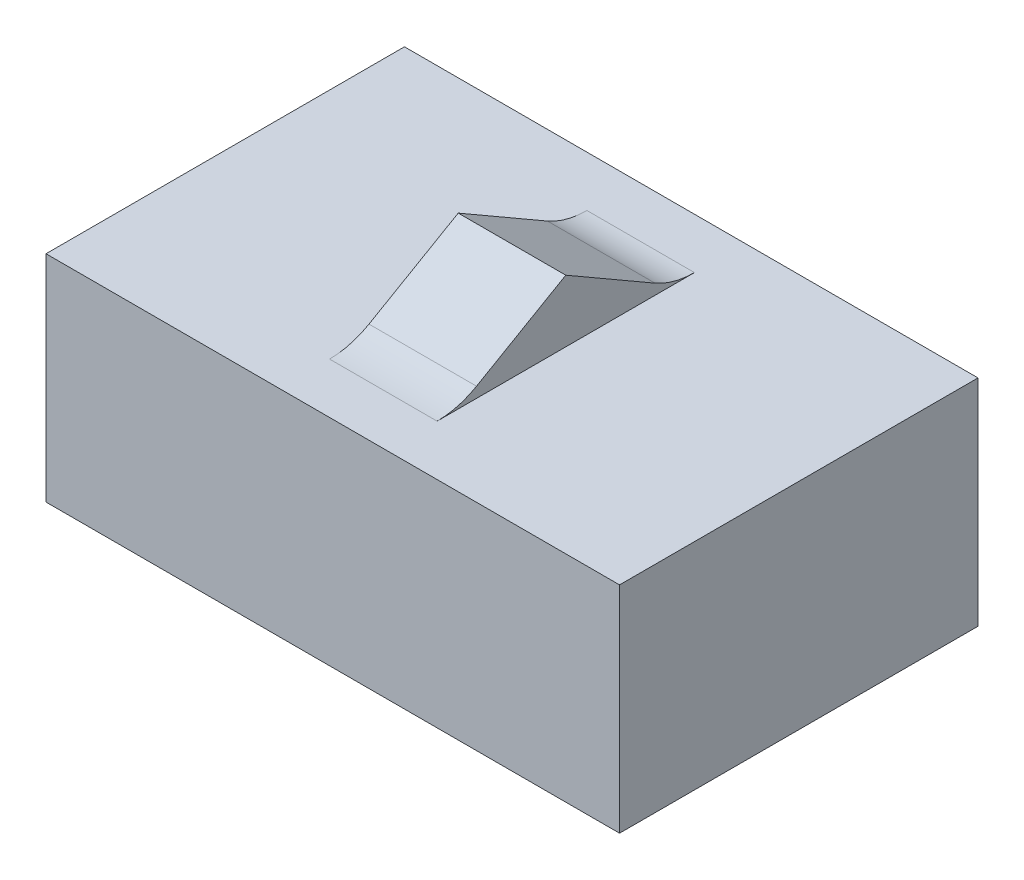
from build123d import *

# Parameters (mm, degrees)
SKETCH_1_W      = 8
SKETCH_1_H      = 5
EXTRUDE_1_DEPTH = 3
EXTRUDE_2_DEPTH = 0.75
FILLET_1_R      = 1.1


with BuildPart() as part:
    # 草图1 → 凸台-拉伸1 (new body)
    with BuildSketch(Plane(origin=(0, 0, 0), x_dir=(1, 0, 0), z_dir=(0, 1, 0))):
        Rectangle(SKETCH_1_W, SKETCH_1_H)
    extrude(amount=EXTRUDE_1_DEPTH)

    # 草图2 → 凸台-拉伸2 (add, symmetric)
    with BuildSketch(Plane(origin=(0, 0, 0), x_dir=(0, 0, -1), z_dir=(1, 0, 0))):
        Polygon((0, 3.866025404), (-1.5, 3), (1.5, 3), align=None)
    extrude(amount=EXTRUDE_2_DEPTH, both=True)

    # 圆角1
    fillet_1_edges = [part.edges().sort_by_distance(p)[0] for p in [
        (0, 3, -1.5),
        (0, 3, 1.5),
    ]]
    fillet(fillet_1_edges, radius=FILLET_1_R)


solid = part.part
